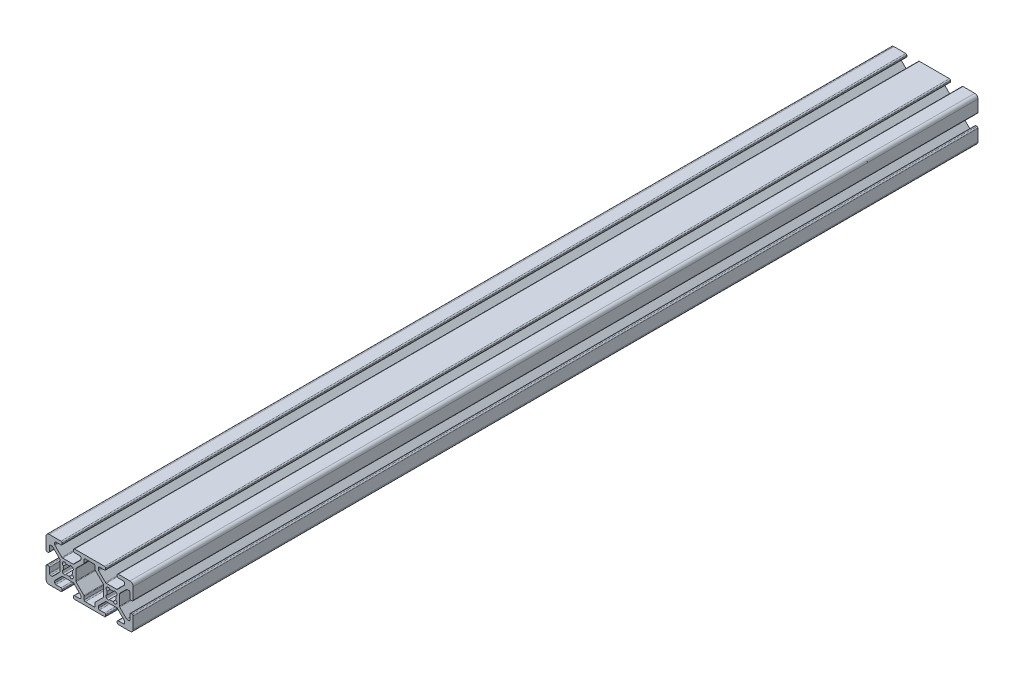
from build123d import *

# Parameters (mm, degrees)
BOSS_EXTRUDE1_DEPTH = 387.35


with BuildPart() as part:
    # Sketch1 → Boss-Extrude1 (new body)
    with BuildSketch(Plane.XY.offset(4000)):
        with BuildLine():
            Line((-40.370498043, -66.586868432), (-37.267417381, -63.483787771))
            ThreePointArc((-37.267417381, -63.483787771), (-37.10261032, -63.373667213), (-36.908207136, -63.334998016))
            Line((-36.908207136, -63.334998016), (-32.140368459, -63.334998016))
            ThreePointArc((-32.140368459, -63.334998016), (-31.945965276, -63.373667213), (-31.781158214, -63.483787771))
            Line((-31.781158214, -63.483787771), (-28.678077553, -66.586868432))
            ThreePointArc((-28.678077553, -66.586868432), (-28.567956995, -66.751675493), (-28.529287798, -66.946078677))
            Line((-28.529287798, -66.946078677), (-28.529287798, -67.671998016))
            ThreePointArc((-28.529287798, -67.671998016), (-28.678077553, -68.031208261), (-29.037287798, -68.179998016))
            Line((-29.037287798, -68.179998016), (-31.386287798, -68.179998016))
            ThreePointArc((-31.386287798, -68.179998016), (-31.745498043, -68.328787771), (-31.894287798, -68.687998016))
            Line((-31.894287798, -68.687998016), (-31.894287798, -69.171998016))
            ThreePointArc((-31.894287798, -69.171998016), (-31.745498043, -69.531208261), (-31.386287798, -69.679998016))
            Line((-31.386287798, -69.679998016), (-17.662287798, -69.679998016))
            ThreePointArc((-17.662287798, -69.679998016), (-17.303077553, -69.531208261), (-17.154287798, -69.171998016))
            Line((-17.154287798, -69.171998016), (-17.154287798, -68.687998016))
            ThreePointArc((-17.154287798, -68.687998016), (-17.303077553, -68.328787771), (-17.662287798, -68.179998016))
            Line((-17.662287798, -68.179998016), (-20.011287798, -68.179998016))
            ThreePointArc((-20.011287798, -68.179998016), (-20.370498043, -68.031208261), (-20.519287798, -67.671998016))
            Line((-20.519287798, -67.671998016), (-20.519287798, -66.946078677))
            ThreePointArc((-20.519287798, -66.946078677), (-20.480618601, -66.751675493), (-20.370498043, -66.586868432))
            Line((-20.370498043, -66.586868432), (-17.267417381, -63.483787771))
            ThreePointArc((-17.267417381, -63.483787771), (-17.10261032, -63.373667213), (-16.908207136, -63.334998016))
            Line((-16.908207136, -63.334998016), (-12.14036846, -63.334998016))
            ThreePointArc((-12.14036846, -63.334998016), (-11.945965276, -63.373667213), (-11.781158215, -63.483787771))
            Line((-11.781158215, -63.483787771), (-8.678077553, -66.586868432))
            ThreePointArc((-8.678077553, -66.586868432), (-8.567956995, -66.751675493), (-8.529287798, -66.946078677))
            Line((-8.529287798, -66.946078677), (-8.529287798, -67.671998016))
            ThreePointArc((-8.529287798, -67.671998016), (-8.678077553, -68.031208261), (-9.037287798, -68.179998016))
            Line((-9.037287798, -68.179998016), (-11.386287798, -68.179998016))
            ThreePointArc((-11.386287798, -68.179998016), (-11.745498043, -68.328787771), (-11.894287798, -68.687998016))
            Line((-11.894287798, -68.687998016), (-11.894287798, -69.171998016))
            ThreePointArc((-11.894287798, -69.171998016), (-11.745498043, -69.531208261), (-11.386287798, -69.679998016))
            Line((-11.386287798, -69.679998016), (-6.024287798, -69.679998016))
            ThreePointArc((-6.024287798, -69.679998016), (-4.963627626, -69.240658188), (-4.524287798, -68.179998016))
            Line((-4.524287798, -68.179998016), (-4.524287798, -62.817998016))
            ThreePointArc((-4.524287798, -62.817998016), (-4.673077553, -62.458787771), (-5.032287798, -62.309998016))
            Line((-5.032287798, -62.309998016), (-5.516287798, -62.309998016))
            ThreePointArc((-5.516287798, -62.309998016), (-5.875498043, -62.458787771), (-6.024287798, -62.817998016))
            Line((-6.024287798, -62.817998016), (-6.024287798, -65.166998016))
            ThreePointArc((-6.024287798, -65.166998016), (-6.173077553, -65.526208261), (-6.532287798, -65.674998016))
            Line((-6.532287798, -65.674998016), (-7.258207136, -65.674998016))
            ThreePointArc((-7.258207136, -65.674998016), (-7.45261032, -65.636328819), (-7.617417381, -65.526208261))
            Line((-7.617417381, -65.526208261), (-10.720498043, -62.423127599))
            ThreePointArc((-10.720498043, -62.423127599), (-10.830618601, -62.258320538), (-10.869287798, -62.063917354))
            Line((-10.869287798, -62.063917354), (-10.869287798, -57.296078677))
            ThreePointArc((-10.869287798, -57.296078677), (-10.830618601, -57.101675493), (-10.720498043, -56.936868432))
            Line((-10.720498043, -56.936868432), (-7.617417382, -53.833787771))
            ThreePointArc((-7.617417382, -53.833787771), (-7.452610321, -53.723667213), (-7.258207137, -53.684998016))
            Line((-7.258207137, -53.684998016), (-6.532287798, -53.684998016))
            ThreePointArc((-6.532287798, -53.684998016), (-6.173077553, -53.833787771), (-6.024287798, -54.192998016))
            Line((-6.024287798, -54.192998016), (-6.024287798, -56.541998016))
            ThreePointArc((-6.024287798, -56.541998016), (-5.875498043, -56.901208261), (-5.516287798, -57.049998016))
            Line((-5.516287798, -57.049998016), (-5.032287798, -57.049998016))
            ThreePointArc((-5.032287798, -57.049998016), (-4.673077553, -56.901208261), (-4.524287798, -56.541998016))
            Line((-4.524287798, -56.541998016), (-4.524287798, -51.179998016))
            ThreePointArc((-4.524287798, -51.179998016), (-4.963627626, -50.119337844), (-6.024287798, -49.679998016))
            Line((-6.024287798, -49.679998016), (-11.386287798, -49.679998016))
            ThreePointArc((-11.386287798, -49.679998016), (-11.745498043, -49.828787771), (-11.894287798, -50.187998016))
            Line((-11.894287798, -50.187998016), (-11.894287798, -50.671998016))
            ThreePointArc((-11.894287798, -50.671998016), (-11.745498043, -51.031208261), (-11.386287798, -51.179998016))
            Line((-11.386287798, -51.179998016), (-9.037287798, -51.179998016))
            ThreePointArc((-9.037287798, -51.179998016), (-8.678077553, -51.328787771), (-8.529287798, -51.687998016))
            Line((-8.529287798, -51.687998016), (-8.529287798, -52.413917354))
            ThreePointArc((-8.529287798, -52.413917354), (-8.567956995, -52.608320538), (-8.678077553, -52.773127599))
            Line((-8.678077553, -52.773127599), (-11.781158215, -55.876208261))
            ThreePointArc((-11.781158215, -55.876208261), (-11.945965276, -55.986328818), (-12.14036846, -56.024998016))
            Line((-12.14036846, -56.024998016), (-16.908207136, -56.024998016))
            ThreePointArc((-16.908207136, -56.024998016), (-17.10261032, -55.986328818), (-17.267417381, -55.876208261))
            Line((-17.267417381, -55.876208261), (-20.370498043, -52.773127599))
            ThreePointArc((-20.370498043, -52.773127599), (-20.480618601, -52.608320538), (-20.519287798, -52.413917354))
            Line((-20.519287798, -52.413917354), (-20.519287798, -51.687998016))
            ThreePointArc((-20.519287798, -51.687998016), (-20.370498043, -51.328787771), (-20.011287798, -51.179998016))
            Line((-20.011287798, -51.179998016), (-17.662287798, -51.179998016))
            ThreePointArc((-17.662287798, -51.179998016), (-17.303077553, -51.031208261), (-17.154287798, -50.671998016))
            Line((-17.154287798, -50.671998016), (-17.154287798, -50.187998016))
            ThreePointArc((-17.154287798, -50.187998016), (-17.303077553, -49.828787771), (-17.662287798, -49.679998016))
            Line((-17.662287798, -49.679998016), (-31.386287798, -49.679998016))
            ThreePointArc((-31.386287798, -49.679998016), (-31.745498043, -49.828787771), (-31.894287798, -50.187998016))
            Line((-31.894287798, -50.187998016), (-31.894287798, -50.671998016))
            ThreePointArc((-31.894287798, -50.671998016), (-31.745498043, -51.031208261), (-31.386287798, -51.179998016))
            Line((-31.386287798, -51.179998016), (-29.037287798, -51.179998016))
            ThreePointArc((-29.037287798, -51.179998016), (-28.678077553, -51.328787771), (-28.529287798, -51.687998016))
            Line((-28.529287798, -51.687998016), (-28.529287798, -52.413917355))
            ThreePointArc((-28.529287798, -52.413917355), (-28.567956995, -52.608320539), (-28.678077553, -52.7731276))
            Line((-28.678077553, -52.7731276), (-31.781158214, -55.876208261))
            ThreePointArc((-31.781158214, -55.876208261), (-31.945965275, -55.986328818), (-32.140368459, -56.024998016))
            Line((-32.140368459, -56.024998016), (-36.908207136, -56.024998016))
            ThreePointArc((-36.908207136, -56.024998016), (-37.10261032, -55.986328818), (-37.267417381, -55.876208261))
            Line((-37.267417381, -55.876208261), (-40.370498043, -52.773127599))
            ThreePointArc((-40.370498043, -52.773127599), (-40.480618601, -52.608320538), (-40.519287798, -52.413917354))
            Line((-40.519287798, -52.413917354), (-40.519287798, -51.687998016))
            ThreePointArc((-40.519287798, -51.687998016), (-40.370498043, -51.328787771), (-40.011287798, -51.179998016))
            Line((-40.011287798, -51.179998016), (-37.662287798, -51.179998016))
            ThreePointArc((-37.662287798, -51.179998016), (-37.303077553, -51.031208261), (-37.154287798, -50.671998016))
            Line((-37.154287798, -50.671998016), (-37.154287798, -50.187998016))
            ThreePointArc((-37.154287798, -50.187998016), (-37.303077553, -49.828787771), (-37.662287798, -49.679998016))
            Line((-37.662287798, -49.679998016), (-43.024287798, -49.679998016))
            ThreePointArc((-43.024287798, -49.679998016), (-44.08494797, -50.119337844), (-44.524287798, -51.179998016))
            Line((-44.524287798, -51.179998016), (-44.524287798, -56.541998016))
            ThreePointArc((-44.524287798, -56.541998016), (-44.375498043, -56.901208261), (-44.016287798, -57.049998016))
            Line((-44.016287798, -57.049998016), (-43.532287798, -57.049998016))
            ThreePointArc((-43.532287798, -57.049998016), (-43.173077553, -56.901208261), (-43.024287798, -56.541998016))
            Line((-43.024287798, -56.541998016), (-43.024287798, -54.192998016))
            ThreePointArc((-43.024287798, -54.192998016), (-42.875498043, -53.833787771), (-42.516287798, -53.684998016))
            Line((-42.516287798, -53.684998016), (-41.790368459, -53.684998016))
            ThreePointArc((-41.790368459, -53.684998016), (-41.595965275, -53.723667213), (-41.431158214, -53.833787771))
            Line((-41.431158214, -53.833787771), (-38.328077553, -56.936868432))
            ThreePointArc((-38.328077553, -56.936868432), (-38.217956995, -57.101675494), (-38.179287798, -57.296078677))
            Line((-38.179287798, -57.296078677), (-38.179287798, -62.063917354))
            ThreePointArc((-38.179287798, -62.063917354), (-38.217956995, -62.258320538), (-38.328077553, -62.423127599))
            Line((-38.328077553, -62.423127599), (-41.431158214, -65.526208261))
            ThreePointArc((-41.431158214, -65.526208261), (-41.595965275, -65.636328819), (-41.790368459, -65.674998016))
            Line((-41.790368459, -65.674998016), (-42.516287798, -65.674998016))
            ThreePointArc((-42.516287798, -65.674998016), (-42.875498043, -65.526208261), (-43.024287798, -65.166998016))
            Line((-43.024287798, -65.166998016), (-43.024287798, -62.817998016))
            ThreePointArc((-43.024287798, -62.817998016), (-43.173077553, -62.458787771), (-43.532287798, -62.309998016))
            Line((-43.532287798, -62.309998016), (-44.016287798, -62.309998016))
            ThreePointArc((-44.016287798, -62.309998016), (-44.375498043, -62.458787771), (-44.524287798, -62.817998016))
            Line((-44.524287798, -62.817998016), (-44.524287798, -68.179998016))
            ThreePointArc((-44.524287798, -68.179998016), (-44.08494797, -69.240658188), (-43.024287798, -69.679998016))
            Line((-43.024287798, -69.679998016), (-37.662287798, -69.679998016))
            ThreePointArc((-37.662287798, -69.679998016), (-37.303077553, -69.531208261), (-37.154287798, -69.171998016))
            Line((-37.154287798, -69.171998016), (-37.154287798, -68.687998016))
            ThreePointArc((-37.154287798, -68.687998016), (-37.303077553, -68.328787771), (-37.662287798, -68.179998016))
            Line((-37.662287798, -68.179998016), (-40.011287798, -68.179998016))
            ThreePointArc((-40.011287798, -68.179998016), (-40.370498043, -68.031208261), (-40.519287798, -67.671998016))
            Line((-40.519287798, -67.671998016), (-40.519287798, -66.946078677))
            ThreePointArc((-40.519287798, -66.946078677), (-40.480618601, -66.751675493), (-40.370498043, -66.586868432))
        make_face()
        with BuildLine():
            Line((-32.219781831, -61.804898859), (-32.399386954, -61.984503982))
            ThreePointArc((-32.399386954, -61.984503982), (-33.167819987, -62.185936033), (-33.72031108, -61.615131522))
            ThreePointArc((-33.72031108, -61.615131522), (-34.524287798, -61.775498016), (-35.328264516, -61.615131522))
            ThreePointArc((-35.328264516, -61.615131522), (-35.880755609, -62.185936032), (-36.649188641, -61.984503982))
            Line((-36.649188641, -61.984503982), (-36.828793764, -61.804898859))
            ThreePointArc((-36.828793764, -61.804898859), (-37.030225815, -61.036465826), (-36.459421304, -60.483974733))
            ThreePointArc((-36.459421304, -60.483974733), (-36.619787798, -59.679998015), (-36.459421304, -58.876021298))
            ThreePointArc((-36.459421304, -58.876021298), (-37.030225814, -58.323530205), (-36.828793763, -57.555097172))
            Line((-36.828793763, -57.555097172), (-36.649188641, -57.37549205))
            ThreePointArc((-36.649188641, -57.37549205), (-35.880755608, -57.174059999), (-35.328264516, -57.74486451))
            ThreePointArc((-35.328264516, -57.74486451), (-34.524287798, -57.584498016), (-33.72031108, -57.74486451))
            ThreePointArc((-33.72031108, -57.74486451), (-33.167819988, -57.174059999), (-32.399386954, -57.375492049))
            Line((-32.399386954, -57.375492049), (-32.219781831, -57.555097172))
            ThreePointArc((-32.219781831, -57.555097172), (-32.018349781, -58.323530205), (-32.589154292, -58.876021298))
            ThreePointArc((-32.589154292, -58.876021298), (-32.428787798, -59.679998016), (-32.589154291, -60.483974733))
            ThreePointArc((-32.589154291, -60.483974733), (-32.018349781, -61.036465826), (-32.219781831, -61.804898859))
        make_face(mode=Mode.SUBTRACT)
        with BuildLine():
            Line((-22.019287798, -66.324758333), (-22.019287798, -67.671998016))
            ThreePointArc((-22.019287798, -67.671998016), (-22.168077553, -68.031208261), (-22.527287798, -68.179998016))
            Line((-22.527287798, -68.179998016), (-26.521287798, -68.179998016))
            ThreePointArc((-26.521287798, -68.179998016), (-26.880498043, -68.031208261), (-27.029287798, -67.671998016))
            Line((-27.029287798, -67.671998016), (-27.029287798, -66.324758333))
            ThreePointArc((-27.029287798, -66.324758333), (-27.067956996, -66.130355149), (-27.178077553, -65.965548088))
            Line((-27.178077553, -65.965548088), (-30.720498043, -62.423127599))
            ThreePointArc((-30.720498043, -62.423127599), (-30.830618601, -62.258320538), (-30.869287798, -62.063917354))
            Line((-30.869287798, -62.063917354), (-30.869287798, -57.296078677))
            ThreePointArc((-30.869287798, -57.296078677), (-30.830618601, -57.101675493), (-30.720498043, -56.936868432))
            Line((-30.720498043, -56.936868432), (-27.178077553, -53.394447943))
            ThreePointArc((-27.178077553, -53.394447943), (-27.067956996, -53.229640882), (-27.029287798, -53.035237698))
            Line((-27.029287798, -53.035237698), (-27.029287798, -51.687998016))
            ThreePointArc((-27.029287798, -51.687998016), (-26.880498043, -51.328787771), (-26.521287798, -51.179998016))
            Line((-26.521287798, -51.179998016), (-22.527287798, -51.179998016))
            ThreePointArc((-22.527287798, -51.179998016), (-22.168077553, -51.328787771), (-22.019287798, -51.687998016))
            Line((-22.019287798, -51.687998016), (-22.019287798, -53.035237698))
            ThreePointArc((-22.019287798, -53.035237698), (-21.980618601, -53.229640881), (-21.870498043, -53.394447942))
            Line((-21.870498043, -53.394447942), (-18.328077554, -56.936868432))
            ThreePointArc((-18.328077554, -56.936868432), (-18.217956996, -57.101675493), (-18.179287798, -57.296078677))
            Line((-18.179287798, -57.296078677), (-18.179287798, -62.063917354))
            ThreePointArc((-18.179287798, -62.063917354), (-18.217956996, -62.258320538), (-18.328077554, -62.423127599))
            Line((-18.328077554, -62.423127599), (-21.870498043, -65.965548089))
            ThreePointArc((-21.870498043, -65.965548089), (-21.980618601, -66.13035515), (-22.019287798, -66.324758333))
        make_face(mode=Mode.SUBTRACT)
        with BuildLine():
            Line((-12.219781831, -61.804898859), (-12.399386954, -61.984503982))
            ThreePointArc((-12.399386954, -61.984503982), (-13.167819987, -62.185936032), (-13.72031108, -61.615131522))
            ThreePointArc((-13.72031108, -61.615131522), (-14.524287798, -61.775498016), (-15.328264516, -61.615131522))
            ThreePointArc((-15.328264516, -61.615131522), (-15.880755609, -62.185936032), (-16.649188642, -61.984503982))
            Line((-16.649188642, -61.984503982), (-16.828793764, -61.804898859))
            ThreePointArc((-16.828793764, -61.804898859), (-17.030225815, -61.036465826), (-16.459421304, -60.483974733))
            ThreePointArc((-16.459421304, -60.483974733), (-16.619787798, -59.679998015), (-16.459421304, -58.876021298))
            ThreePointArc((-16.459421304, -58.876021298), (-17.030225814, -58.323530205), (-16.828793764, -57.555097172))
            Line((-16.828793764, -57.555097172), (-16.649188641, -57.37549205))
            ThreePointArc((-16.649188641, -57.37549205), (-15.880755609, -57.17406), (-15.328264516, -57.74486451))
            ThreePointArc((-15.328264516, -57.74486451), (-14.524287798, -57.584498016), (-13.72031108, -57.74486451))
            ThreePointArc((-13.72031108, -57.74486451), (-13.167819987, -57.174059999), (-12.399386954, -57.37549205))
            Line((-12.399386954, -57.37549205), (-12.219781832, -57.555097172))
            ThreePointArc((-12.219781832, -57.555097172), (-12.018349781, -58.323530205), (-12.589154292, -58.876021298))
            ThreePointArc((-12.589154292, -58.876021298), (-12.428787798, -59.679998016), (-12.589154292, -60.483974733))
            ThreePointArc((-12.589154292, -60.483974733), (-12.018349781, -61.036465826), (-12.219781831, -61.804898859))
        make_face(mode=Mode.SUBTRACT)
    extrude(amount=-BOSS_EXTRUDE1_DEPTH)


solid = part.part
